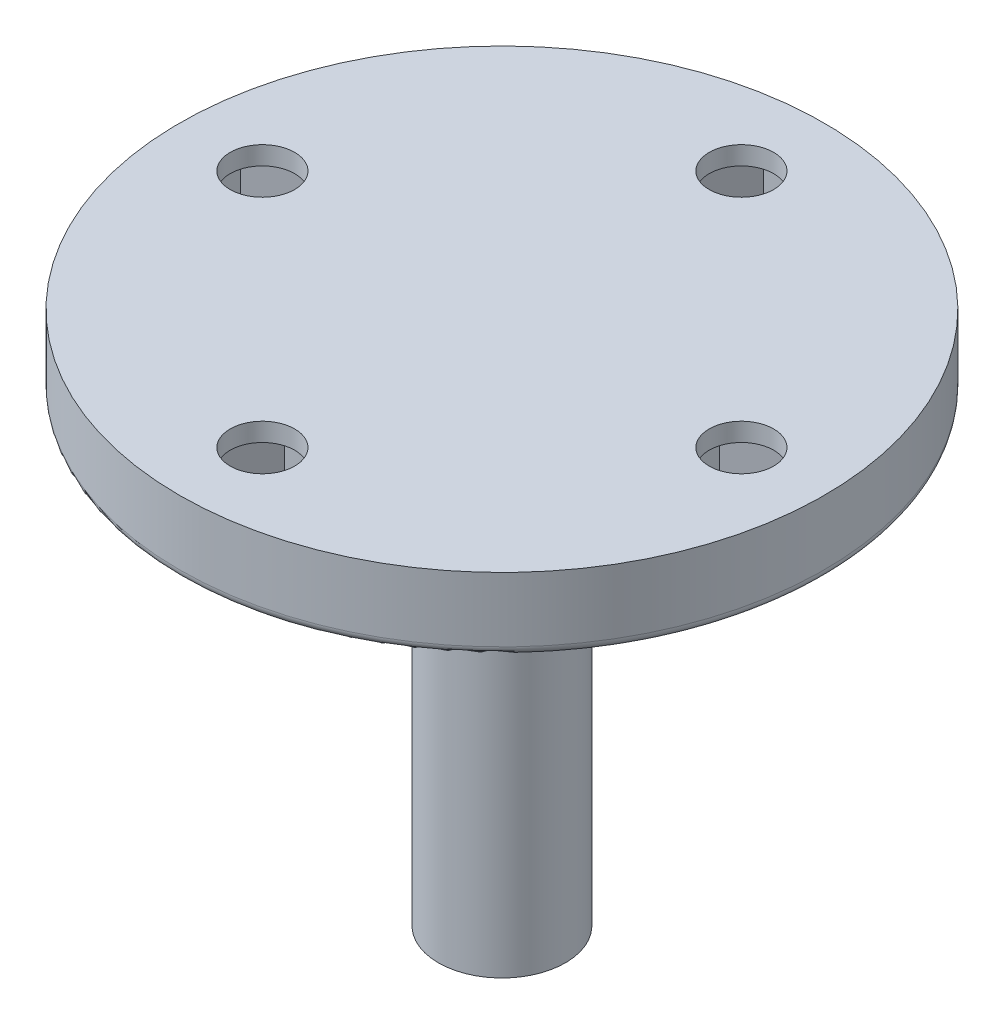
from build123d import *

# Parameters (mm, degrees)
SKETCH_1_R          = 3.45
EXTRUDE_1_DEPTH     = 23
CUT_EXTRUDE_1_DEPTH = 5.5
SKETCH_3_R          = 4
EXTRUDE_2_DEPTH     = 2
SKETCH_4_R          = 17.5
EXTRUDE_3_DEPTH     = 4
CUT_EXTRUDE_2_DEPTH = 3
SKETCH_6_R          = 1.75
CUT_EXTRUDE_3_DEPTH = 2
FILLET_1_R          = 0.5
FILLET_2_R          = 1


with BuildPart() as part:
    # Эскиз1 → Бобышка-Вытянуть1 (new body)
    with BuildSketch(Plane(origin=(0, 0, 0), x_dir=(1, 0, 0), z_dir=(0, 1, 0))):
        Circle(SKETCH_1_R)
    extrude(amount=EXTRUDE_1_DEPTH)

    # Эскиз2 → Вырез-Вытянуть1 (cut)
    with BuildSketch(Plane.XZ):
        with BuildLine():
            Line((-1.55, 2.391652149), (-1.55, -2.391652149))
            ThreePointArc((-1.55, -2.391652149), (0, -2.85), (1.55, -2.391652149))
            Line((1.55, -2.391652149), (1.55, 2.391652149))
            ThreePointArc((1.55, 2.391652149), (0, 2.85), (-1.55, 2.391652149))
        make_face()
    extrude(amount=-CUT_EXTRUDE_1_DEPTH, mode=Mode.SUBTRACT)

    # Эскиз3 → Бобышка-Вытянуть2 (add)
    with BuildSketch(Plane(origin=(0, 23, 0), x_dir=(1, 0, 0), z_dir=(0, 1, 0))):
        Circle(SKETCH_3_R)
    extrude(amount=EXTRUDE_2_DEPTH)

    # Эскиз4 → Бобышка-Вытянуть3 (add)
    with BuildSketch(Plane(origin=(0, 25, 0), x_dir=(1, 0, 0), z_dir=(0, 1, 0))):
        Circle(SKETCH_4_R)
    extrude(amount=EXTRUDE_3_DEPTH)

    # Эскиз5 → Вырез-Вытянуть2 (cut)
    with BuildSketch(Plane.XZ.offset(-25)):
        Polygon((13, -3.279349529), (15.84, -1.639674764), (15.84, 1.639674764), (13, 3.279349529), (10.16, 1.639674764), (10.16, -1.639674764), align=None)
        Polygon((3.279349529, 13), (1.639674764, 15.84), (-1.639674764, 15.84), (-3.279349529, 13), (-1.639674764, 10.16), (1.639674764, 10.16), align=None)
        Polygon((-3.279349529, -13), (-1.639674764, -15.84), (1.639674764, -15.84), (3.279349529, -13), (1.639674764, -10.16), (-1.639674764, -10.16), align=None)
        Polygon((-13, 3.279349529), (-15.84, 1.639674764), (-15.84, -1.639674764), (-13, -3.279349529), (-10.16, -1.639674764), (-10.16, 1.639674764), align=None)
    extrude(amount=-CUT_EXTRUDE_2_DEPTH, mode=Mode.SUBTRACT)

    # Эскиз6 → Вырез-Вытянуть3 (cut, through all)
    with BuildSketch(Plane.XZ.offset(-28)):
        with Locations((0, 13)):
            Circle(SKETCH_6_R)
        with Locations((13, 0)):
            Circle(SKETCH_6_R)
        with Locations((0, -13)):
            Circle(SKETCH_6_R)
        with Locations((-13, 0)):
            Circle(SKETCH_6_R)
    extrude(amount=-CUT_EXTRUDE_3_DEPTH, mode=Mode.SUBTRACT)

    # Скругление1
    fillet_1_edges = [part.edges().sort_by_distance(p)[0] for p in [
        (-17.5, 25, 0),
    ]]
    fillet(fillet_1_edges, radius=FILLET_1_R)

    # Скругление2
    fillet_2_edges = [part.edges().sort_by_distance(p)[0] for p in [
        (-4, 25, 0),
    ]]
    fillet(fillet_2_edges, radius=FILLET_2_R)


solid = part.part
